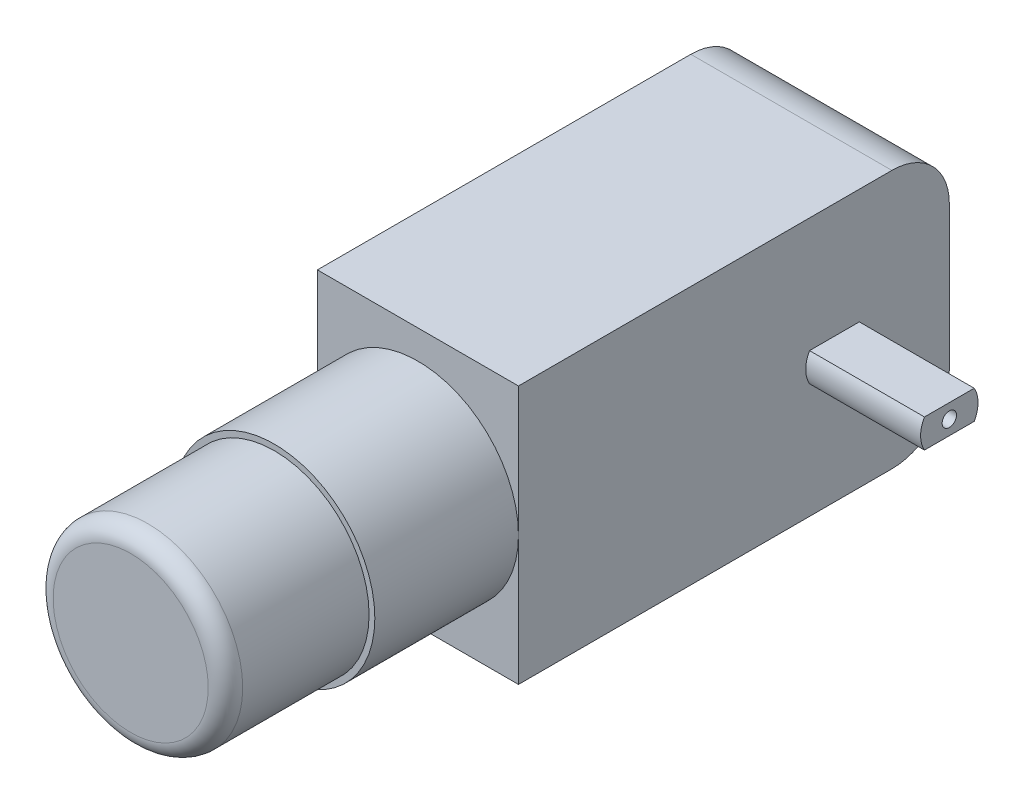
from build123d import *

# Parameters (mm, degrees)
SKETCH1_W           = 37.5
SKETCH1_H           = 22.5
BOSS_EXTRUDE2_DEPTH = 17.5
SKETCH2_R           = 0.625
BOSS_EXTRUDE3_DEPTH = 10
SKETCH3_R           = 8.75
BOSS_EXTRUDE4_DEPTH = 12.5
SKETCH4_R           = 8.25
BOSS_EXTRUDE5_DEPTH = 12.5
FILLET2_R           = 1.5
FILLET3_R           = 5
BOSS_EXTRUDE6_DEPTH = 10


with BuildPart() as part:
    # Sketch1 → Boss-Extrude2 (new body)
    with BuildSketch(Plane(origin=(0, 0, 0), x_dir=(0, 0, -1), z_dir=(1, 0, 0))):
        Rectangle(SKETCH1_W, SKETCH1_H)
    extrude(amount=BOSS_EXTRUDE2_DEPTH)

    # Sketch2 → Boss-Extrude3 (add)
    with BuildSketch(Plane(origin=(17.5, 0, 0), x_dir=(0, 0, -1), z_dir=(1, 0, 0))):
        with BuildLine():
            Line((10.915063509, 1.246479188), (6.584936491, 1.246479188))
            ThreePointArc((6.584936491, 1.246479188), (6.25, -0.003520812), (6.584936491, -1.253520812))
            Line((6.584936491, -1.253520812), (10.915063509, -1.253520812))
            ThreePointArc((10.915063509, -1.253520812), (11.25, -0.003520812), (10.915063509, 1.246479188))
        make_face()
        with Locations((8.75, -0.003520812)):
            Circle(SKETCH2_R, mode=Mode.SUBTRACT)
    extrude(amount=BOSS_EXTRUDE3_DEPTH)

    # Sketch3 → Boss-Extrude4 (add)
    with BuildSketch(Plane.XY.offset(18.75)):
        with Locations((8.75, 0)):
            Circle(SKETCH3_R)
    extrude(amount=BOSS_EXTRUDE4_DEPTH)

    # Sketch4 → Boss-Extrude5 (add)
    with BuildSketch(Plane.XY.offset(31.25)):
        with Locations((8.75, 0)):
            Circle(SKETCH4_R)
    extrude(amount=BOSS_EXTRUDE5_DEPTH)

    # Fillet2
    fillet2_edges = [part.edges().sort_by_distance(p)[0] for p in [
        (0.5, 0, 43.75),
    ]]
    fillet(fillet2_edges, radius=FILLET2_R)

    # Fillet3
    fillet3_edges = [part.edges().sort_by_distance(p)[0] for p in [
        (8.75, -11.25, -18.75),
        (8.75, 11.25, -18.75),
    ]]
    fillet(fillet3_edges, radius=FILLET3_R)

    # Sketch5 → Boss-Extrude6 (add)
    with BuildSketch(Plane.ZY):
        with BuildLine():
            ThreePointArc((-10.915063509, 1.25), (-11.164814566, 0.647047613), (-11.25, 0))
            Line((-11.25, 0), (-8.75, 0))
            Line((-8.75, 0), (-6.25, 0))
            ThreePointArc((-6.25, 0), (-6.335185434, 0.647047613), (-6.584936491, 1.25))
            Line((-6.584936491, 1.25), (-10.915063509, 1.25))
        make_face()
        with BuildLine():
            Line((-8.75, 0), (-11.25, 0))
            ThreePointArc((-11.25, 0), (-11.164814566, -0.647047613), (-10.915063509, -1.25))
            Line((-10.915063509, -1.25), (-6.584936491, -1.25))
            ThreePointArc((-6.584936491, -1.25), (-6.335185434, -0.647047613), (-6.25, 0))
            Line((-6.25, 0), (-8.75, 0))
        make_face()
    extrude(amount=BOSS_EXTRUDE6_DEPTH)


solid = part.part
